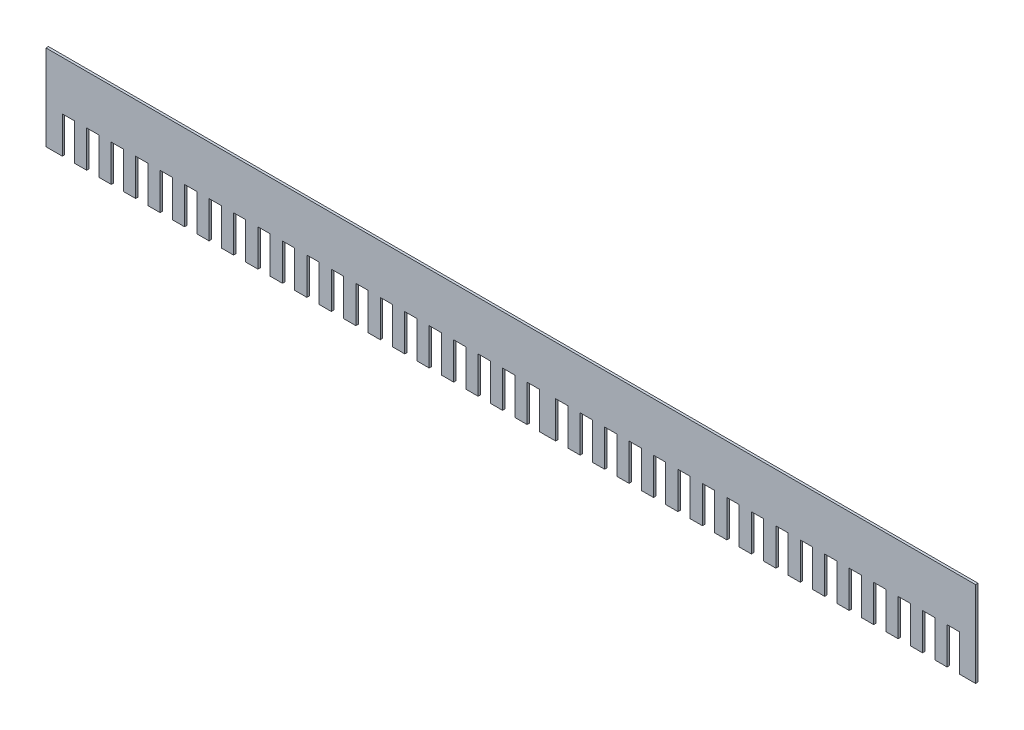
from build123d import *

# Parameters (mm, degrees)
BOSS_EXTRUDE1_DEPTH = 1


with BuildPart() as part:
    # Sketch1 → Boss-Extrude1 (new body)
    with BuildSketch(Plane.XY):
        Polygon((-180.819610652, -0.465116279), (-180.819610652, -15.465116279), (-175.819610652, -15.465116279), (-175.819610652, -0.465116279), (-170.819610652, -0.465116279), (-170.819610652, -15.465116279), (-165.819610652, -15.465116279), (-165.819610652, -0.465116279), (-160.819610652, -0.465116279), (-160.819610652, -15.465116279), (-155.819610652, -15.465116279), (-155.819610652, -0.465116279), (-150.819610652, -0.465116279), (-150.819610652, -15.465116279), (-145.819610652, -15.465116279), (-145.819610652, -0.465116279), (-140.819610652, -0.465116279), (-140.819610652, -15.465116279), (-135.819610652, -15.465116279), (-135.819610652, -0.465116279), (-130.819610652, -0.465116279), (-130.819610652, -15.465116279), (-125.819610652, -15.465116279), (-125.819610652, -0.465116279), (-120.819610652, -0.465116279), (-120.819610652, -15.465116279), (-115.819610652, -15.465116279), (-115.819610652, -0.465116279), (-110.819610652, -0.465116279), (-110.819610652, -15.465116279), (-105.819610652, -15.465116279), (-105.819610652, -0.465116279), (-100.819610652, -0.465116279), (-100.819610652, -15.465116279), (-95.819610652, -15.465116279), (-95.819610652, -0.465116279), (-90.819610652, -0.465116279), (-90.819610652, -15.465116279), (-85.819610652, -15.465116279), (-85.819610652, -0.465116279), (-80.819610652, -0.465116279), (-80.819610652, -15.465116279), (-75.819610652, -15.465116279), (-75.819610652, -0.465116279), (-70.819610652, -0.465116279), (-70.819610652, -15.465116279), (-65.819610652, -15.465116279), (-65.819610652, -0.465116279), (-60.819610652, -0.465116279), (-60.819610652, -15.465116279), (-55.819610652, -15.465116279), (-55.819610652, -0.465116279), (-50.819610652, -0.465116279), (-50.819610652, -15.465116279), (-45.819610652, -15.465116279), (-45.819610652, -0.465116279), (-40.819610652, -0.465116279), (-40.819610652, -15.465116279), (-35.819610652, -15.465116279), (-35.819610652, -0.465116279), (-30.819610652, -0.465116279), (-30.819610652, -15.465116279), (-25.819610652, -15.465116279), (-25.819610652, -0.465116279), (-20.819610652, -0.465116279), (-20.819610652, -15.465116279), (-15.819610652, -15.465116279), (-15.819610652, -0.465116279), (-10.819610652, -0.465116279), (-10.819610652, -15.465116279), (-5.819610652, -15.465116279), (-5.819610652, -0.465116279), (-0.819610652, -0.465116279), (-0.819610652, -15.465116279), (5.874690211, -15.465116279), (5.874690211, -0.465116279), (10.874690211, -0.465116279), (10.874690211, -15.465116279), (15.874690211, -15.465116279), (15.874690211, -0.465116279), (20.874690211, -0.465116279), (20.874690211, -15.465116279), (25.874690211, -15.465116279), (25.874690211, -0.465116279), (30.874690211, -0.465116279), (30.874690211, -15.465116279), (35.874690211, -15.465116279), (35.874690211, -0.465116279), (40.874690211, -0.465116279), (40.874690211, -15.465116279), (45.874690211, -15.465116279), (45.874690211, -0.465116279), (50.874690211, -0.465116279), (50.874690211, -15.465116279), (55.874690211, -15.465116279), (55.874690211, -0.465116279), (60.874690211, -0.465116279), (60.874690211, -15.465116279), (65.874690211, -15.465116279), (65.874690211, -0.465116279), (70.874690211, -0.465116279), (70.874690211, -15.465116279), (75.874690211, -15.465116279), (75.874690211, -0.465116279), (80.874690211, -0.465116279), (80.874690211, -15.465116279), (85.874690211, -15.465116279), (85.874690211, -0.465116279), (90.874690211, -0.465116279), (90.874690211, -15.465116279), (95.874690211, -15.465116279), (95.874690211, -0.465116279), (100.874690211, -0.465116279), (100.874690211, -15.465116279), (105.874690211, -15.465116279), (105.874690211, -0.465116279), (110.874690211, -0.465116279), (110.874690211, -15.465116279), (115.874690211, -15.465116279), (115.874690211, -0.465116279), (120.874690211, -0.465116279), (120.874690211, -15.465116279), (125.874690211, -15.465116279), (125.874690211, -0.465116279), (130.874690211, -0.465116279), (130.874690211, -15.465116279), (135.874690211, -15.465116279), (135.874690211, -0.465116279), (140.874690211, -0.465116279), (140.874690211, -15.465116279), (145.874690211, -15.465116279), (145.874690211, -0.465116279), (150.874690211, -0.465116279), (150.874690211, -15.465116279), (155.874690211, -15.465116279), (155.874690211, -0.465116279), (160.874690211, -0.465116279), (160.874690211, -15.465116279), (165.874690211, -15.465116279), (165.874690211, -0.465116279), (170.874690211, -0.465116279), (170.874690211, -15.465116279), (177.52753978, -15.465116279), (177.52753978, 19.534883721), (-202.47246022, 19.534883721), (-202.47246022, -15.465116279), (-195.819610652, -15.465116279), (-195.819610652, -0.465116279), (-190.819610652, -0.465116279), (-190.819610652, -15.465116279), (-185.819610652, -15.465116279), (-185.819610652, -0.465116279), align=None)
    extrude(amount=BOSS_EXTRUDE1_DEPTH)


solid = part.part
